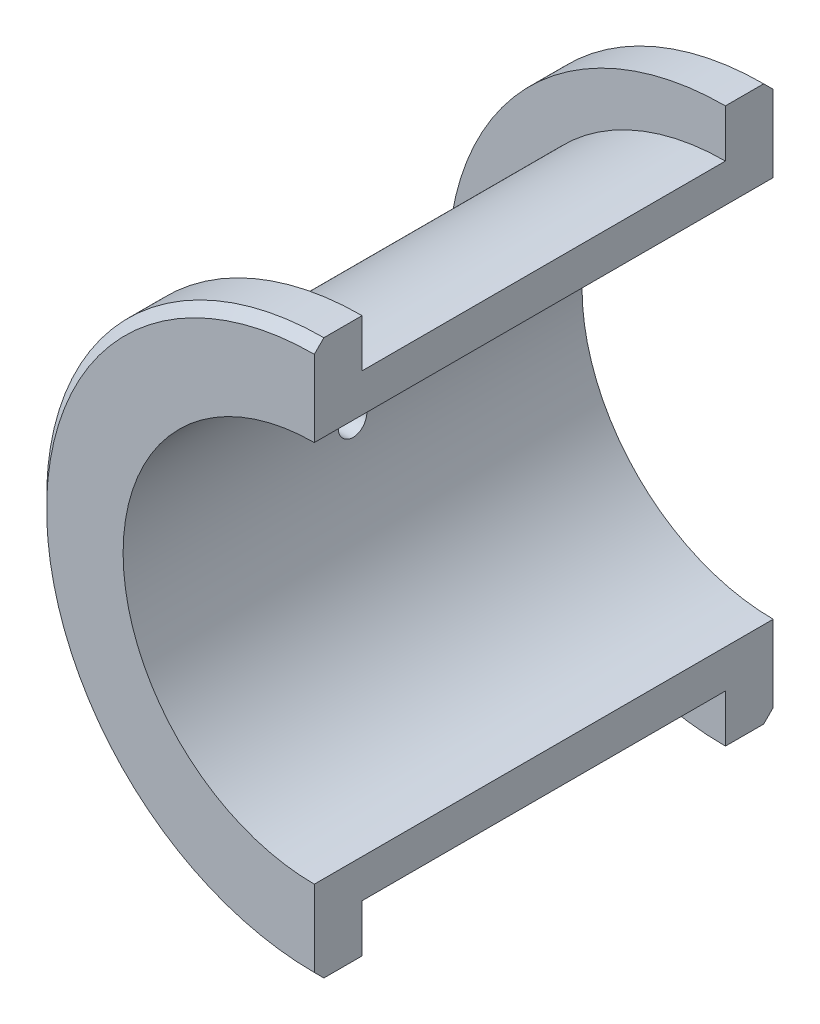
from build123d import *

# Parameters (mm, degrees)
SKETCH_1_R           = 24
SKETCH_1_R_2         = 20
EXTRUDE_1_DEPTH      = 24
EXTRUDE_START        = -5
SKETCH_2_R           = 29
SKETCH_2_R_2         = 24
EXTRUDE_2_DEPTH      = 5
SKETCH_5_W           = 29
SKETCH_5_H           = 58
CUT_EXTRUDE_1_DEPTH  = 64.134776471
CHAMFER_2_SIZE       = 1
EXTRUDE_3_REACH      = 79.518
EXTRUDE_3_END_RADIUS = 24
EXTRUDE_START_2      = -30
SKETCH_6_R           = 4
SKETCH_6_R_2         = 1.5
SKETCH_6_2_R         = 1.5
CUT_EXTRUDE_2_DEPTH  = 49.135226249


with BuildPart() as part:
    # Эскиз1 → Бобышка-Вытянуть1 (new body)
    with BuildSketch(Plane.XY):
        Circle(SKETCH_1_R)
        Circle(SKETCH_1_R_2, mode=Mode.SUBTRACT)
    extrude(amount=EXTRUDE_1_DEPTH)

    # Эскиз2 → Бобышка-Вытянуть2 (add)
    with BuildSketch(Plane.XY.offset(24).offset(EXTRUDE_START)):
        Circle(SKETCH_2_R)
        Circle(SKETCH_2_R_2, mode=Mode.SUBTRACT)
    extrude(amount=EXTRUDE_2_DEPTH)

    # Зеркальное отражение1: part across plane


with BuildPart() as part_1:
    add(part.part)
    add(part.part.mirror(Plane.XY))

    # Эскиз5 → Вырез-Вытянуть1 (cut, through all)
    with BuildSketch(Plane.XY.offset(24)):
        with Locations((14.5, 0)):
            Rectangle(SKETCH_5_W, SKETCH_5_H)
    extrude(amount=-CUT_EXTRUDE_1_DEPTH, mode=Mode.SUBTRACT)

    # Фаска2
    chamfer_2_edges = [part_1.edges().sort_by_distance(p)[0] for p in [
        (-29, 0, -24),
        (-29, 0, 24),
    ]]
    chamfer(chamfer_2_edges, length=CHAMFER_2_SIZE)

    # Бобышка-Вытянуть3: up to this cylinder (the profile starts outside it)
    extrude_3_end = Plane(origin=(0, 0, 3.886863), z_dir=(0, 0, -1)) * Cylinder(EXTRUDE_3_END_RADIUS, 208.036, mode=Mode.PRIVATE)
    # Эскиз6 → Бобышка-Вытянуть3 (add, up to the surface)
    with BuildSketch(Plane(origin=(0, 0, 0), x_dir=(0, 0, -1), z_dir=(1, 0, 0)).offset(EXTRUDE_START_2), mode=Mode.PRIVATE) as extrude_3_sk1:
        Circle(SKETCH_6_R)
        Circle(SKETCH_6_R_2, mode=Mode.SUBTRACT)
    extrude_3_tool1 = extrude(extrude_3_sk1.sketch, amount=EXTRUDE_3_REACH, mode=Mode.PRIVATE) - extrude_3_end
    add(extrude_3_tool1.solids().sort_by_distance((-30, 0, 3.886863))[0])

    # Эскиз6<2> → Вырез-Вытянуть2 (cut, through all)
    with BuildSketch(Plane(origin=(0, 0, 0), x_dir=(0, 0, -1), z_dir=(1, 0, 0))):
        Circle(SKETCH_6_2_R)
    extrude(amount=-CUT_EXTRUDE_2_DEPTH, mode=Mode.SUBTRACT)


solid = part_1.part
